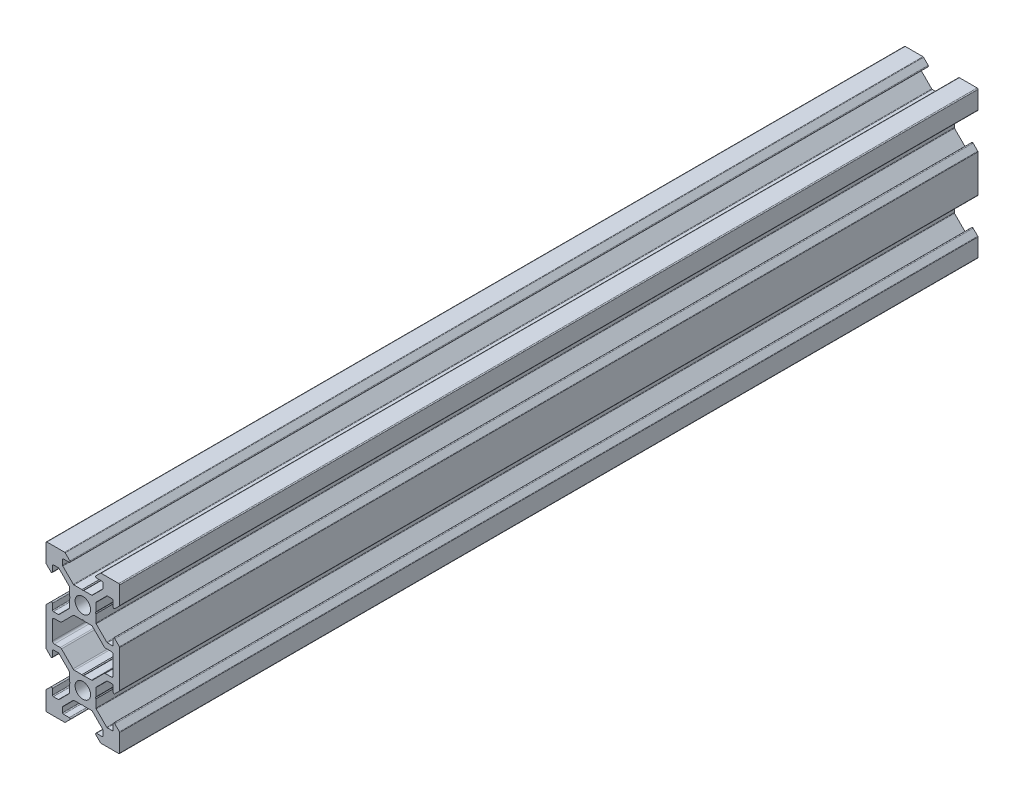
from build123d import *

# Parameters (mm, degrees)
SKETCH1_R           = 2.1
BOSS_EXTRUDE1_DEPTH = 233.04
FILLET1_R           = 0.25
FILLET2_R           = 0.5
CUT_EXTRUDE1_DEPTH  = 234.04


with BuildPart() as part:
    # Sketch1 → Boss-Extrude1 (new body)
    with BuildSketch(Plane.XY):
        Polygon((3.560660172, -2.5), (3.560660172, 2.5), (6.560660172, 5.5), (8.252142372, 5.5), (8.252142372, 3.1), (10, 4.847857628), (10, 10), (4.847857628, 10), (3.1, 8.252142372), (5.5, 8.252142372), (5.5, 6.560660172), (2.5, 3.560660172), (-2.5, 3.560660172), (-5.5, 6.560660172), (-5.5, 8.252142372), (-3.1, 8.252142372), (-4.847857628, 10), (-10, 10), (-10, 4.847857628), (-8.252142372, 3.1), (-8.252142372, 5.5), (-6.560660172, 5.5), (-3.560660172, 2.5), (-3.560660172, -2.5), (-6.560660172, -5.5), (-8.252142372, -5.5), (-8.252142372, -3.1), (-10, -4.847857628), (-10, -7), (-10, -13), (-10, -15.152142372), (-8.252142372, -16.9), (-8.252142372, -14.5), (-6.560660172, -14.5), (-3.560660172, -17.5), (-3.560660172, -22.5), (-6.560660172, -25.5), (-8.252142372, -25.5), (-8.252142372, -23.1), (-10, -24.847857628), (-10, -30), (-4.847857628, -30), (-3.1, -28.252142372), (-5.5, -28.252142372), (-5.5, -26.560660172), (-2.5, -23.560660172), (2.5, -23.560660172), (5.5, -26.560660172), (5.5, -28.252142372), (3.1, -28.252142372), (4.847857628, -30), (10, -30), (10, -24.847857628), (8.252142372, -23.1), (8.252142372, -25.5), (6.560660172, -25.5), (3.560660172, -22.5), (3.560660172, -17.5), (6.560660172, -14.5), (8.252142372, -14.5), (8.252142372, -16.9), (10, -15.152142372), (10, -13), (10, -7), (10, -4.847857628), (8.252142372, -3.1), (8.252142372, -5.5), (6.560660172, -5.5), align=None)
        Circle(SKETCH1_R, mode=Mode.SUBTRACT)
        with Locations((0, -20)):
            Circle(SKETCH1_R, mode=Mode.SUBTRACT)
        Polygon((2.5, -3.560660172), (-2.5, -3.560660172), (-5.5, -6.560660172), (-5.939339828, -7), (-8.252142372, -7), (-8.252142372, -13), (-5.939339828, -13), (-5.5, -13.439339828), (-2.5, -16.439339828), (2.5, -16.439339828), (5.5, -13.439339828), (5.939339828, -13), (8.252142372, -13), (8.252142372, -7), (5.939339828, -7), (5.5, -6.560660172), align=None, mode=Mode.SUBTRACT)
    extrude(amount=BOSS_EXTRUDE1_DEPTH)

    # Fillet1
    fillet1_edges = [part.edges().sort_by_distance(p)[0] for p in [
        (5.5, 6.560660172, 116.52),
        (5.5, 8.252142372, 116.52),
        (3.1, 8.252142372, 116.52),
        (4.847857628, 10, 116.52),
        (10, 10, 116.52),
        (10, 4.847857628, 116.52),
        (8.252142372, 3.1, 116.52),
        (8.252142372, 5.5, 116.52),
        (6.560660172, 5.5, 116.52),
        (3.560660172, 2.5, 116.52),
        (3.560660172, -2.5, 116.52),
        (6.560660172, -5.5, 116.52),
        (8.252142372, -5.5, 116.52),
        (8.252142372, -3.1, 116.52),
        (10, -4.847857628, 116.52),
        (10, -15.152142372, 116.52),
        (8.252142372, -16.9, 116.52),
        (8.252142372, -14.5, 116.52),
        (6.560660172, -14.5, 116.52),
        (3.560660172, -17.5, 116.52),
        (3.560660172, -22.5, 116.52),
        (6.560660172, -25.5, 116.52),
        (8.252142372, -25.5, 116.52),
        (8.252142372, -23.1, 116.52),
        (10, -24.847857628, 116.52),
        (10, -30, 116.52),
        (4.847857628, -30, 116.52),
        (3.1, -28.252142372, 116.52),
        (5.5, -28.252142372, 116.52),
        (5.5, -26.560660172, 116.52),
        (2.5, -23.560660172, 116.52),
        (-2.5, -23.560660172, 116.52),
        (-5.5, -26.560660172, 116.52),
        (-5.5, -28.252142372, 116.52),
        (-3.1, -28.252142372, 116.52),
        (-4.847857628, -30, 116.52),
        (-10, -30, 116.52),
        (-10, -24.847857628, 116.52),
        (-8.252142372, -23.1, 116.52),
        (-8.252142372, -25.5, 116.52),
        (-6.560660172, -25.5, 116.52),
        (-3.560660172, -22.5, 116.52),
        (-3.560660172, -17.5, 116.52),
        (-6.560660172, -14.5, 116.52),
        (-8.252142372, -14.5, 116.52),
        (-8.252142372, -16.9, 116.52),
        (-10, -15.152142372, 116.52),
        (-10, -4.847857628, 116.52),
        (-8.252142372, -3.1, 116.52),
        (-8.252142372, -5.5, 116.52),
        (-6.560660172, -5.5, 116.52),
        (-3.560660172, -2.5, 116.52),
        (-3.560660172, 2.5, 116.52),
        (-6.560660172, 5.5, 116.52),
        (-8.252142372, 5.5, 116.52),
        (-8.252142372, 3.1, 116.52),
        (-10, 4.847857628, 116.52),
        (-10, 10, 116.52),
        (-4.847857628, 10, 116.52),
        (-3.1, 8.252142372, 116.52),
        (-5.5, 8.252142372, 116.52),
        (-5.5, 6.560660172, 116.52),
        (-2.5, 3.560660172, 116.52),
        (2.5, 3.560660172, 116.52),
    ]]
    fillet(fillet1_edges, radius=FILLET1_R)

    # Fillet2
    fillet2_edges = [part.edges().sort_by_distance(p)[0] for p in [
        (-2.5, -3.560660172, 116.52),
        (-5.939339828, -7, 116.52),
        (-8.252142372, -7, 116.52),
        (-8.252142372, -13, 116.52),
        (-5.939339828, -13, 116.52),
        (-2.5, -16.439339828, 116.52),
        (2.5, -16.439339828, 116.52),
        (5.939339828, -13, 116.52),
        (8.252142372, -13, 116.52),
        (8.252142372, -7, 116.52),
        (5.939339828, -7, 116.52),
        (2.5, -3.560660172, 116.52),
    ]]
    fillet(fillet2_edges, radius=FILLET2_R)

    # Sketch2 → Cut-Extrude1 (cut, through all)
    with BuildSketch(Plane.XY.offset(233.04)):
        Polygon((0, 3.398953432), (-0.242280927, 3.560660172), (0.242280927, 3.560660172), align=None)
        Polygon((0, -3.398953432), (0.242280927, -3.560660172), (-0.242280927, -3.560660172), align=None)
        Polygon((3.560660172, 0.242280927), (3.560660172, -0.242280927), (3.398953432, 0), align=None)
        Polygon((-3.560660172, 0.242280927), (-3.560660172, -0.242280927), (-3.398953432, 0), align=None)
        Polygon((-3.398953432, -20), (-3.560660172, -20.242280927), (-3.560660172, -19.757719073), align=None)
        Polygon((3.398953432, -20), (3.560660172, -19.757719073), (3.560660172, -20.242280927), align=None)
        Polygon((-0.242280927, -16.439339828), (0.242280927, -16.439339828), (0, -16.601046568), align=None)
        Polygon((-0.242280927, -23.560660172), (0.242280927, -23.560660172), (0, -23.398953432), align=None)
    extrude(amount=-CUT_EXTRUDE1_DEPTH, mode=Mode.SUBTRACT)


solid = part.part
